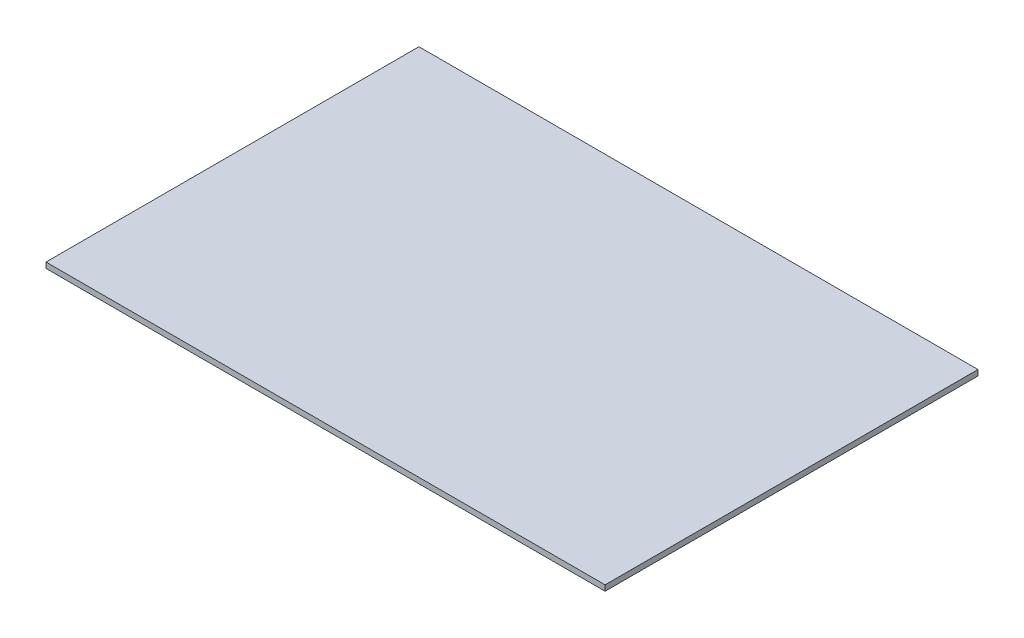
from build123d import *

# Parameters (mm, degrees)
ESQUISSE1_W      = 1000
ESQUISSE1_H      = 667
EXTRUSION1_DEPTH = 10


with BuildPart() as part:
    # Esquisse1 → Extrusion1 (new body)
    with BuildSketch(Plane(origin=(0, 0, 0), x_dir=(1, 0, 0), z_dir=(0, 1, 0))):
        with Locations((500, 333.5)):
            Rectangle(ESQUISSE1_W, ESQUISSE1_H)
    extrude(amount=EXTRUSION1_DEPTH)


solid = part.part
